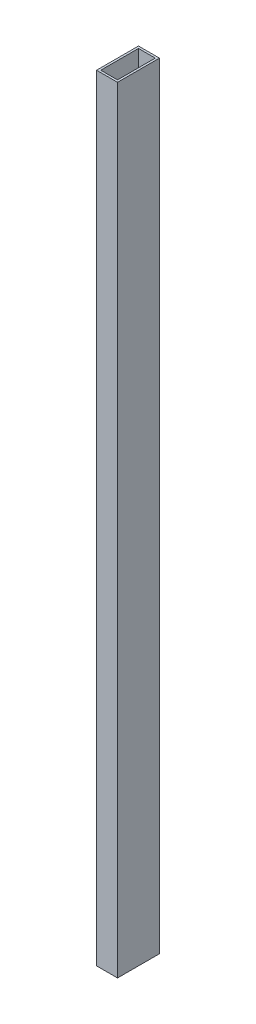
from build123d import *

# Parameters (mm, degrees)
SKETCH_1_W      = 20
SKETCH_1_H      = 40
SKETCH_1_W_2    = 16
SKETCH_1_H_2    = 36
EXTRUDE_1_DEPTH = 740


with BuildPart() as part:
    # Эскиз1 → Вытянуть-Тонкостенный1 (new body)
    with BuildSketch(Plane(origin=(0, 0, 0), x_dir=(1, 0, 0), z_dir=(0, 1, 0))):
        Rectangle(SKETCH_1_W, SKETCH_1_H)
        Rectangle(SKETCH_1_W_2, SKETCH_1_H_2, mode=Mode.SUBTRACT)
    extrude(amount=EXTRUDE_1_DEPTH)


solid = part.part
